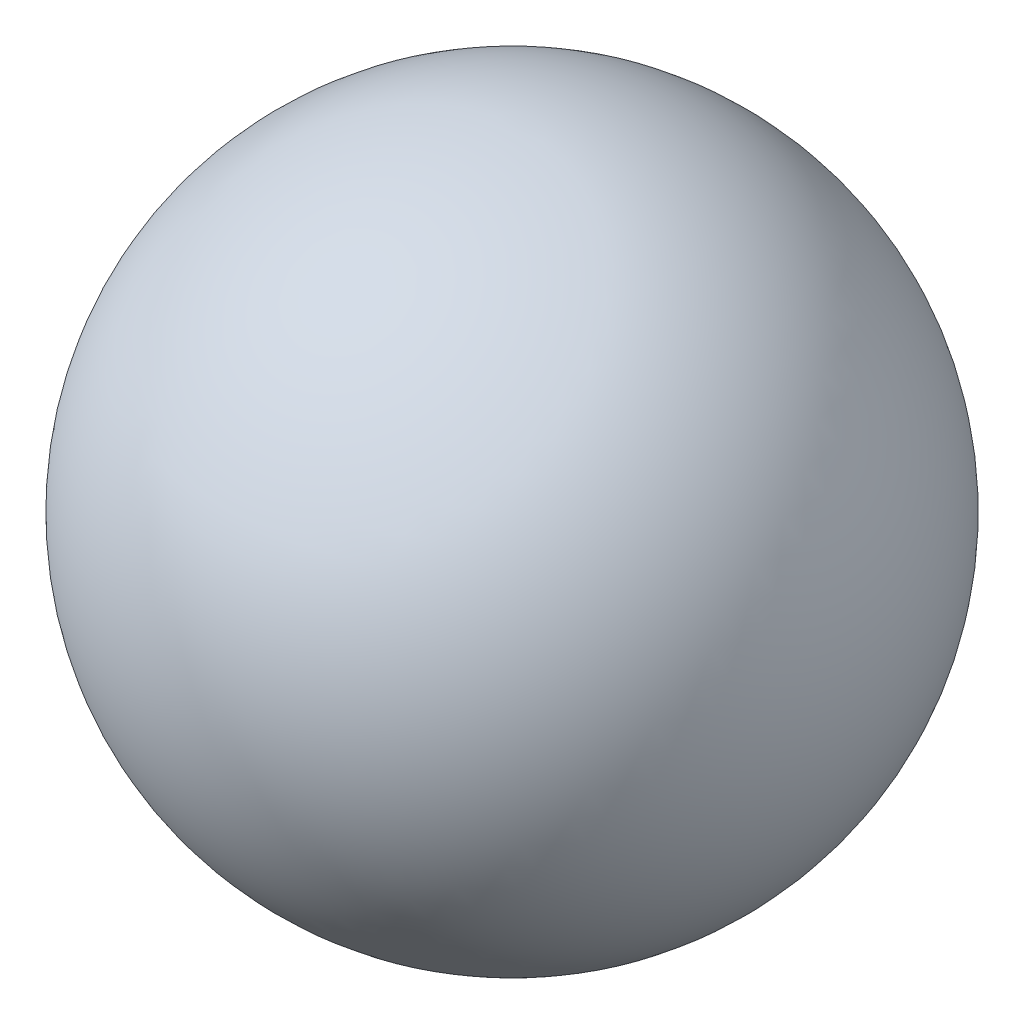
from build123d import *


with BuildPart() as part:
    # Эскиз1 → Повернуть1 (revolve)
    with BuildSketch(Plane.XY):
        with BuildLine():
            Line((0, 94.242962652), (0, -94.242962652))
            ThreePointArc((0, -94.242962652), (94.242962652, 0), (0, 94.242962652))
        make_face()
    revolve(axis=Axis((0, 103.435400236, 0), (0, -1, 0)))


solid = part.part
